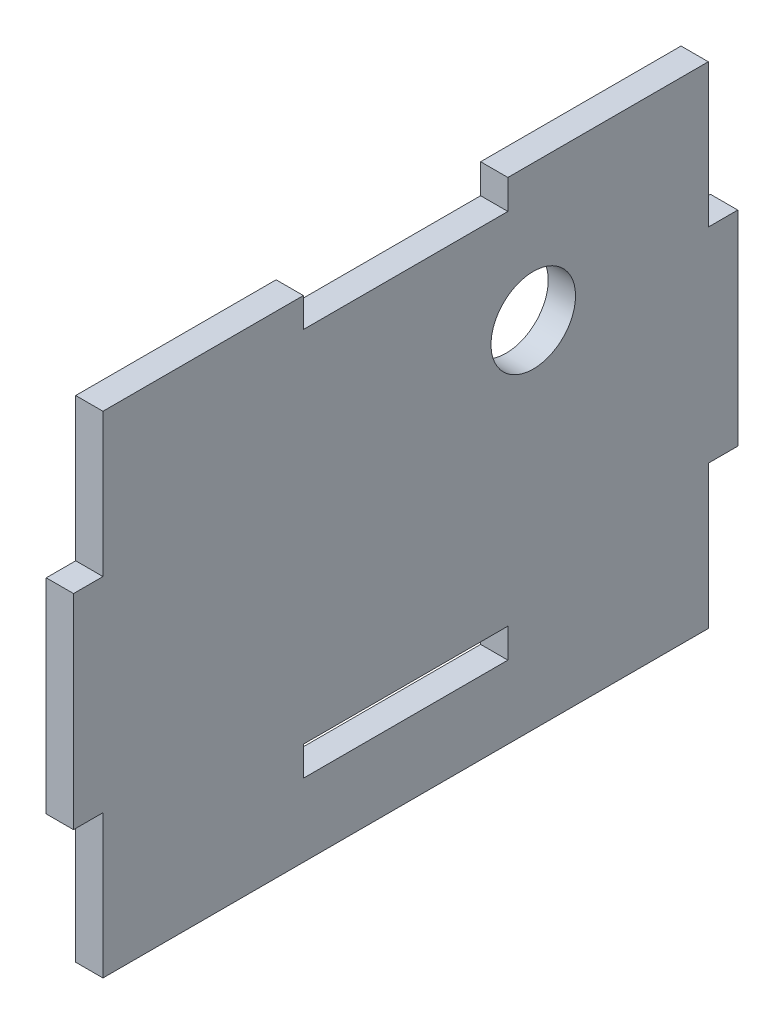
from build123d import *

# Parameters (mm, degrees)
SKETCH1_W           = 56.388
SKETCH1_H           = 45.72
BOSS_EXTRUDE1_DEPTH = 2.54
SKETCH2_W           = 2.7432
SKETCH2_H           = 19.05
BOSS_EXTRUDE2_DEPTH = 2.54
SKETCH3_W           = 19.05
SKETCH3_H           = 2.7432
CUT_EXTRUDE1_DEPTH  = 3.54
SKETCH4_R           = 3.937
CUT_EXTRUDE2_DEPTH  = 3.54


with BuildPart() as part:
    # Sketch1 → Boss-Extrude1 (new body)
    with BuildSketch(Plane(origin=(0, 0, 0), x_dir=(0, 0, -1), z_dir=(1, 0, 0))):
        Rectangle(SKETCH1_W, SKETCH1_H)
    extrude(amount=BOSS_EXTRUDE1_DEPTH)

    # Sketch2 → Boss-Extrude2 (add)
    with BuildSketch(Plane(origin=(2.54, 0, 0), x_dir=(0, 0, -1), z_dir=(1, 0, 0))):
        with Locations((-29.5656, 0)):
            Rectangle(SKETCH2_W, SKETCH2_H)
        with Locations((29.5656, 0)):
            Rectangle(SKETCH2_W, SKETCH2_H)
    extrude(amount=-BOSS_EXTRUDE2_DEPTH)

    # Sketch3 → Cut-Extrude1 (cut, through all)
    with BuildSketch(Plane(origin=(2.54, 0, 0), x_dir=(0, 0, -1), z_dir=(1, 0, 0))):
        with Locations((0, 21.4884)):
            Rectangle(SKETCH3_W, SKETCH3_H)
        with Locations((0, -14.7066)):
            Rectangle(SKETCH3_W, SKETCH3_H)
    extrude(amount=-CUT_EXTRUDE1_DEPTH, mode=Mode.SUBTRACT)

    # Sketch4 → Cut-Extrude2 (cut, through all)
    with BuildSketch(Plane(origin=(2.54, 0, 0), x_dir=(0, 0, -1), z_dir=(1, 0, 0))):
        with Locations((11.8872, 10.16)):
            Circle(SKETCH4_R)
    extrude(amount=-CUT_EXTRUDE2_DEPTH, mode=Mode.SUBTRACT)


solid = part.part
